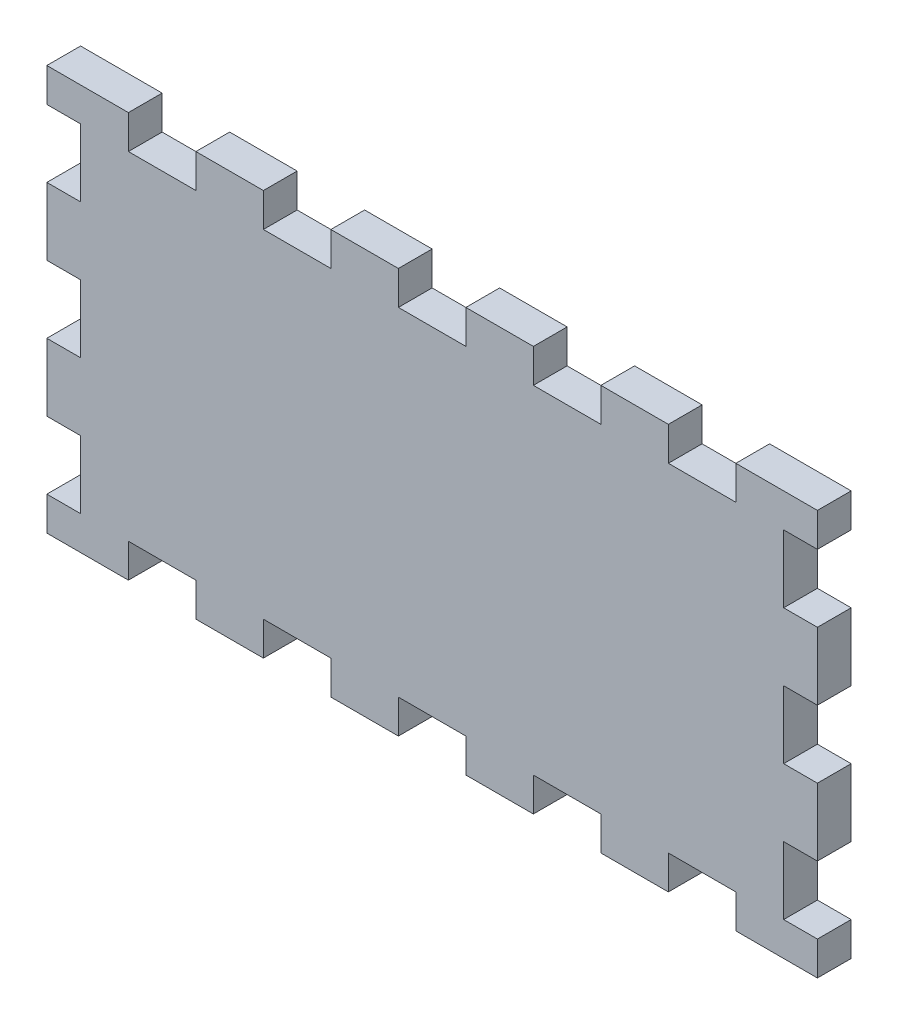
from build123d import *

# Parameters (mm, degrees)
SKETCH2_W           = 8.5
SKETCH2_H           = 6
BOSS_EXTRUDE1_DEPTH = 6
SKETCH3_W           = 6
SKETCH3_H           = 12
CUT_EXTRUDE1_DEPTH  = 6


with BuildPart() as part:
    # Sketch2 → Boss-Extrude1 (new body)
    with BuildSketch(Plane.XY):
        Polygon((-68.5, 72), (-68.5, 36), (68.5, 36), (68.5, 72), (54, 72), (54, 66), (42, 66), (42, 72), (30, 72), (30, 66), (18, 66), (18, 72), (6, 72), (6, 66), (-6, 66), (-6, 72), (-18, 72), (-18, 66), (-30, 66), (-30, 72), (-42, 72), (-42, 66), (-54, 66), (-54, 72), align=None)
        Polygon((-68.5, 36), (-68.5, 0), (-62.5, 0), (-62.5, 6), (-54, 6), (-42, 6), (-42, 0), (-30, 0), (-30, 6), (-18, 6), (-18, 0), (-6, 0), (-6, 6), (6, 6), (6, 0), (18, 0), (18, 6), (30, 6), (30, 0), (42, 0), (42, 6), (54, 6), (54, 0), (68.5, 0), (68.5, 36), align=None)
        with Locations((-58.25, 3)):
            Rectangle(SKETCH2_W, SKETCH2_H)
    extrude(amount=BOSS_EXTRUDE1_DEPTH)

    # Sketch3 → Cut-Extrude1 (cut)
    with BuildSketch(Plane.XY.offset(6)):
        with Locations((-65.5, 60)):
            Rectangle(SKETCH3_W, SKETCH3_H)
        with Locations((-65.5, 12)):
            Rectangle(SKETCH3_W, SKETCH3_H)
        with Locations((65.5, 36)):
            Rectangle(SKETCH3_W, SKETCH3_H)
        with Locations((65.5, 12)):
            Rectangle(SKETCH3_W, SKETCH3_H)
        with Locations((-65.5, 36)):
            Rectangle(SKETCH3_W, SKETCH3_H)
        with Locations((65.5, 60)):
            Rectangle(SKETCH3_W, SKETCH3_H)
    extrude(amount=-CUT_EXTRUDE1_DEPTH, mode=Mode.SUBTRACT)


solid = part.part
